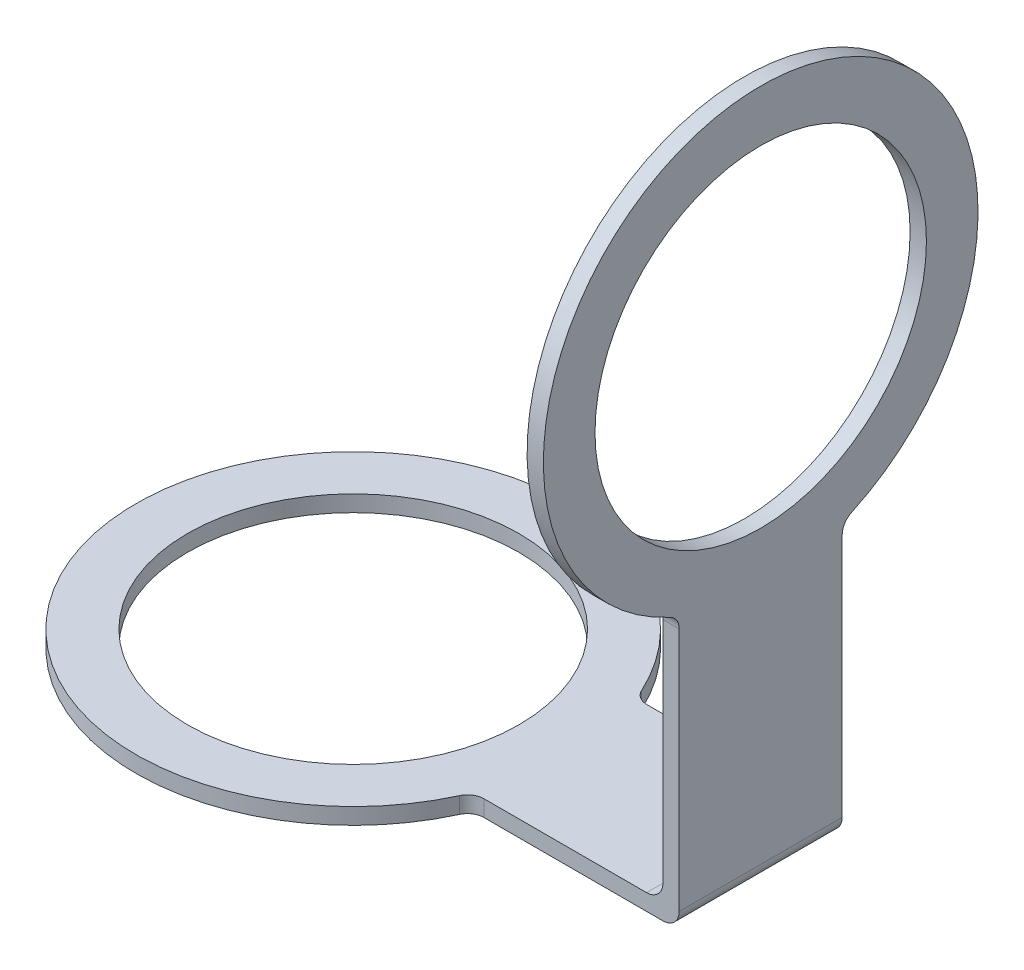
from build123d import *

# Parameters (mm, degrees)
SKETCH1_R           = 40
SKETCH1_R_2         = 30.5
BOSS_EXTRUDE1_DEPTH = 3
SKETCH2_W           = 40
SKETCH2_H           = 30
BOSS_EXTRUDE2_DEPTH = 3
SKETCH3_R           = 30.5
BOSS_EXTRUDE3_DEPTH = 3
FILLET1_R           = 3
FILLET2_R           = 3


with BuildPart() as part:
    # Sketch1 → Boss-Extrude1 (new body)
    with BuildSketch(Plane(origin=(0, 0, 0), x_dir=(1, 0, 0), z_dir=(0, 1, 0))):
        Circle(SKETCH1_R)
        Circle(SKETCH1_R_2, mode=Mode.SUBTRACT)
    extrude(amount=BOSS_EXTRUDE1_DEPTH)

    # Sketch2 → Boss-Extrude2 (add)
    with BuildSketch(Plane(origin=(0, 3, 0), x_dir=(1, 0, 0), z_dir=(0, 1, 0))):
        with Locations((55, 0)):
            Rectangle(SKETCH2_W, SKETCH2_H)
    extrude(amount=-BOSS_EXTRUDE2_DEPTH)

    # Sketch3 → Boss-Extrude3 (add)
    with BuildSketch(Plane(origin=(75, 0, 0), x_dir=(0, 0, -1), z_dir=(1, 0, 0))):
        with BuildLine():
            Line((-15, 0), (15, 0))
            Line((15, 0), (15, 50))
            ThreePointArc((15, 50), (0, 127.080992435), (-15, 50))
            Line((-15, 50), (-15, 0))
        make_face()
        with Locations((0, 87.080992435)):
            Circle(SKETCH3_R, mode=Mode.SUBTRACT)
    extrude(amount=-BOSS_EXTRUDE3_DEPTH)

    # Fillet1
    fillet1_edges = [part.edges().sort_by_distance(p)[0] for p in [
        (37.080992435, 1.5, 15),
        (37.080992435, 1.5, -15),
        (73.5, 50, 15),
        (73.5, 50, -15),
    ]]
    fillet(fillet1_edges, radius=FILLET1_R)

    # Fillet2
    fillet2_edges = [part.edges().sort_by_distance(p)[0] for p in [
        (75, 0, 0),
        (72, 3, 0),
    ]]
    fillet(fillet2_edges, radius=FILLET2_R)


solid = part.part
